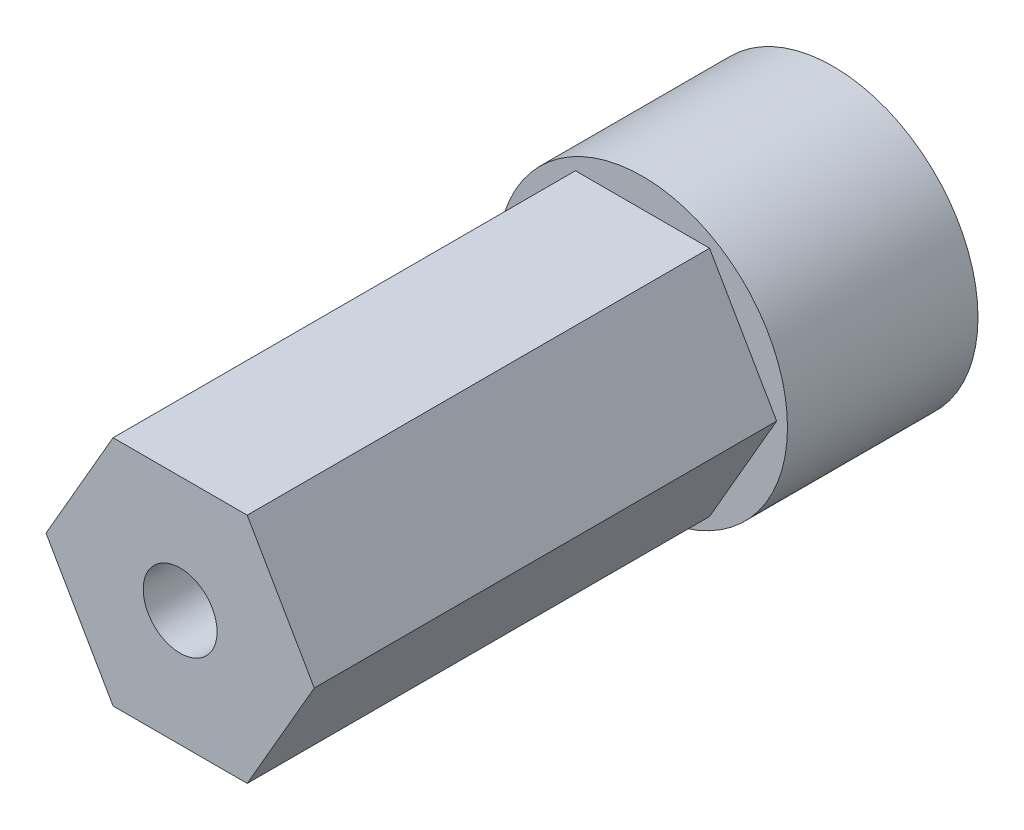
from build123d import *

# Parameters (mm, degrees)
SKETCH2_R           = 7.9248
BOSS_EXTRUDE1_DEPTH = 10.414
BOSS_EXTRUDE2_DEPTH = 25.273
SKETCH4_R           = 2.0193
CUT_EXTRUDE1_DEPTH  = 22.86


with BuildPart() as part:
    # Sketch2 → Boss-Extrude1 (new body)
    with BuildSketch(Plane.XY):
        Circle(SKETCH2_R)
    extrude(amount=BOSS_EXTRUDE1_DEPTH)

    # Sketch3 → Boss-Extrude2 (add)
    with BuildSketch(Plane.XY.offset(10.414)):
        Polygon((7.332348419, 0), (3.666174209, 6.35), (-3.666174209, 6.35), (-7.332348419, 0), (-3.666174209, -6.35), (3.666174209, -6.35), align=None)
    extrude(amount=BOSS_EXTRUDE2_DEPTH)

    # Sketch4 → Cut-Extrude1 (cut)
    with BuildSketch(Plane.XY.offset(35.687)):
        Circle(SKETCH4_R)
    extrude(amount=-CUT_EXTRUDE1_DEPTH, mode=Mode.SUBTRACT)


solid = part.part
